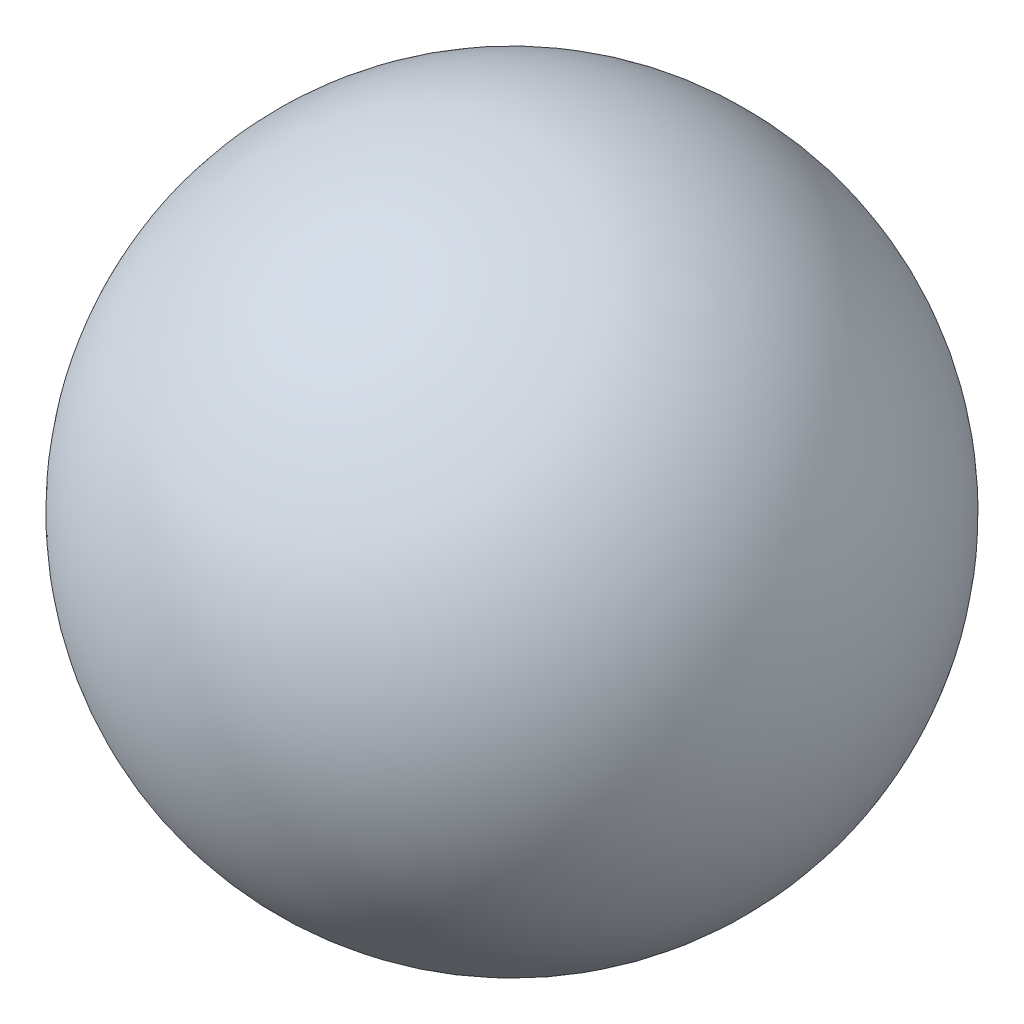
from build123d import *


with BuildPart() as part:
    # Эскиз1 → Повернуть1 (revolve)
    with BuildSketch(Plane.XY):
        with BuildLine():
            Line((-0.6, 0), (0.6, 0))
            ThreePointArc((0.6, 0), (0, 0.6), (-0.6, 0))
        make_face()
    revolve(axis=Axis((-0.6, 0, 0), (1, 0, 0)))


solid = part.part
